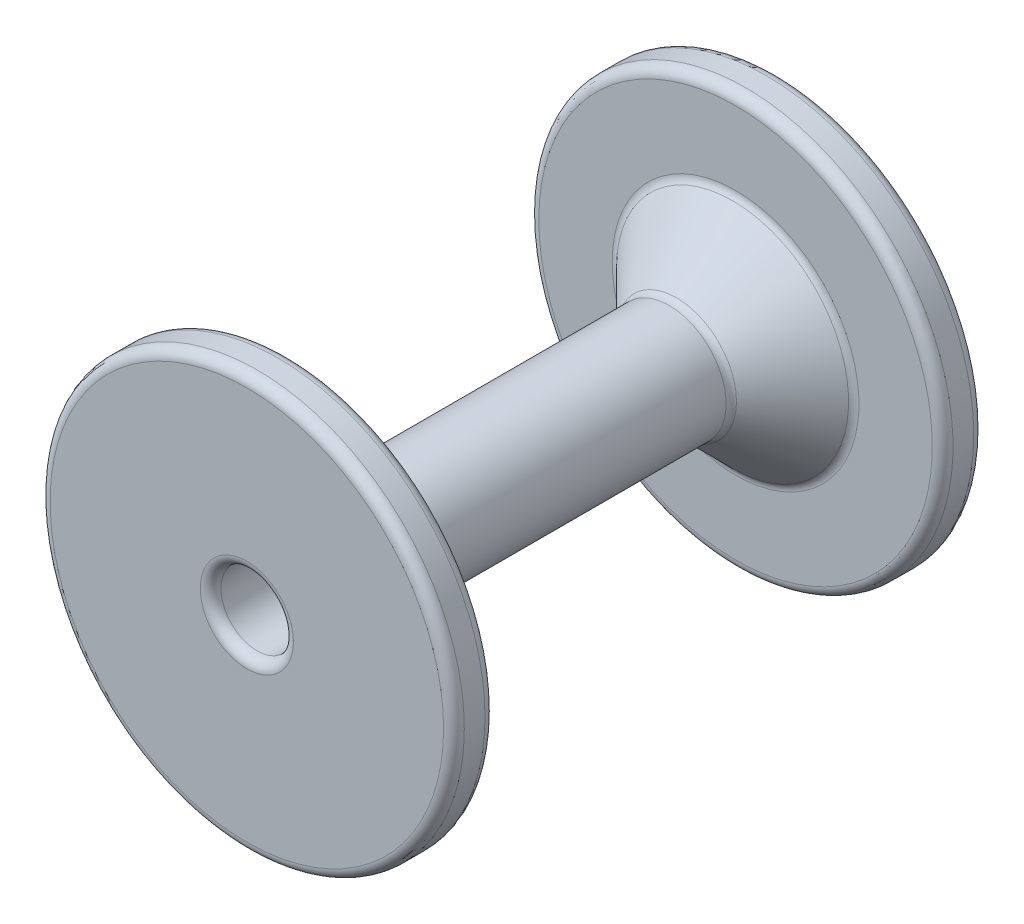
from build123d import *

# Parameters (mm, degrees)
SKETCH1_R           = 2.75
SKETCH1_R_2         = 1.75
BOSS_EXTRUDE1_DEPTH = 12.8
SKETCH2_R           = 10
SKETCH2_R_2         = 2.75
BOSS_EXTRUDE2_DEPTH = 2
CHAMFER3_SIZE       = 3
CUT_EXTRUDE1_DEPTH  = 2.4
FILLET2_R           = 0.5


with BuildPart() as part:
    # Sketch1 → Boss-Extrude1 (new body, symmetric)
    with BuildSketch(Plane.XY):
        Circle(SKETCH1_R)
        Circle(SKETCH1_R_2, mode=Mode.SUBTRACT)
    extrude(amount=BOSS_EXTRUDE1_DEPTH, both=True)

    # Sketch2 → Boss-Extrude2 (add)
    with BuildSketch(Plane.XY.offset(12.8)):
        Circle(SKETCH2_R)
        Circle(SKETCH2_R_2, mode=Mode.SUBTRACT)
    boss_extrude2 = extrude(amount=-BOSS_EXTRUDE2_DEPTH)

    # Mirror1: Boss-Extrude2 across plane
    add(boss_extrude2.mirror(Plane.XY))

    # Chamfer3
    chamfer3_edges = [part.edges().sort_by_distance(p)[0] for p in [
        (-2.75, 0, -10.8),
    ]]
    chamfer(chamfer3_edges, length=CHAMFER3_SIZE)

    # Sketch4 → Cut-Extrude1 (cut)
    with BuildSketch(Plane(origin=(0, 0, -12.8), x_dir=(-1, 0, 0), z_dir=(0, 0, -1))):
        Polygon((1.58771324, 2.75), (-1.58771324, 2.75), (-3.175426481, 0), (-1.58771324, -2.75), (1.58771324, -2.75), (3.175426481, 0), align=None)
    extrude(amount=-CUT_EXTRUDE1_DEPTH, mode=Mode.SUBTRACT)

    # Fillet2
    fillet2_edges = [part.edges().sort_by_distance(p)[0] for p in [
        (-10, 0, 10.8),
        (-10, 0, 12.8),
        (-10, 0, -10.8),
        (-10, 0, -12.8),
        (-5.75, 0, -10.8),
        (-2.75, 0, -7.8),
        (-2.38156986, 1.375, -12.8),
        (0, 2.75, -12.8),
        (2.38156986, 1.375, -12.8),
        (2.38156986, -1.375, -12.8),
        (0, -2.75, -12.8),
        (-2.38156986, -1.375, -12.8),
        (-1.75, 0, 12.8),
        (-2.75, 0, 10.8),
    ]]
    fillet(fillet2_edges, radius=FILLET2_R)


solid = part.part
